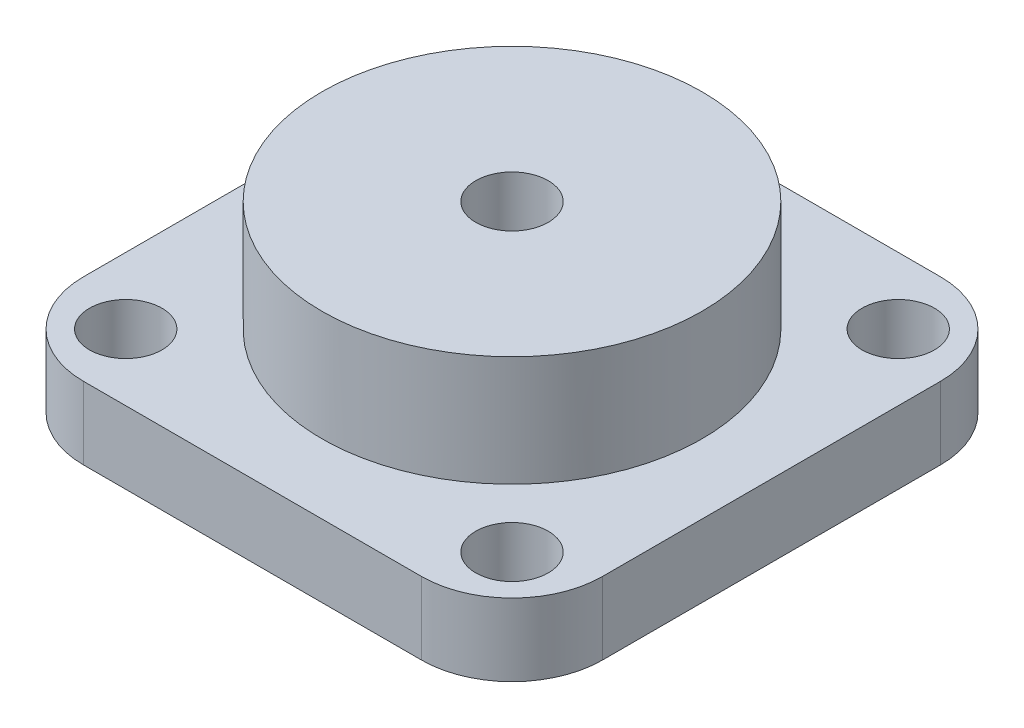
from build123d import *

# Parameters (mm, degrees)
BOSS_EXTRUDE1_DEPTH = 12
SKETCH2_R           = 6
CUT_EXTRUDE1_DEPTH  = 12
SKETCH3_R           = 31.5
BOSS_EXTRUDE2_DEPTH = 18.3
SKETCH4_R           = 6
CUT_EXTRUDE2_DEPTH  = 31.3


with BuildPart() as part:
    # Sketch1 → Boss-Extrude1 (new body)
    with BuildSketch(Plane(origin=(0, 0, 0), x_dir=(1, 0, 0), z_dir=(0, 1, 0))):
        with BuildLine():
            Line((-15, 0), (-71, 0))
            ThreePointArc((-71, 0), (-81.606601718, -4.393398282), (-86, -15))
            Line((-86, -15), (-86, -71))
            ThreePointArc((-86, -71), (-81.606601718, -81.606601718), (-71, -86))
            Line((-71, -86), (-15, -86))
            ThreePointArc((-15, -86), (-4.393398282, -81.606601718), (0, -71))
            Line((0, -71), (0, -15))
            ThreePointArc((0, -15), (-4.393398282, -4.393398282), (-15, 0))
        make_face()
    extrude(amount=BOSS_EXTRUDE1_DEPTH)

    # Sketch2 → Cut-Extrude1 (cut)
    with BuildSketch(Plane(origin=(0, 12, 0), x_dir=(1, 0, 0), z_dir=(0, 1, 0))):
        with Locations((-75, -11)):
            Circle(SKETCH2_R)
        with Locations((-11, -11)):
            Circle(SKETCH2_R)
        with Locations((-11, -75)):
            Circle(SKETCH2_R)
        with Locations((-75, -75)):
            Circle(SKETCH2_R)
    extrude(amount=-CUT_EXTRUDE1_DEPTH, mode=Mode.SUBTRACT)

    # Sketch3 → Boss-Extrude2 (add)
    with BuildSketch(Plane(origin=(0, 12, 0), x_dir=(1, 0, 0), z_dir=(0, 1, 0))):
        with Locations((-43, -43)):
            Circle(SKETCH3_R)
    extrude(amount=BOSS_EXTRUDE2_DEPTH)

    # Sketch4 → Cut-Extrude2 (cut, through all)
    with BuildSketch(Plane(origin=(0, 30.3, 0), x_dir=(1, 0, 0), z_dir=(0, 1, 0))):
        with Locations((-43, -43)):
            Circle(SKETCH4_R)
    extrude(amount=-CUT_EXTRUDE2_DEPTH, mode=Mode.SUBTRACT)


solid = part.part
